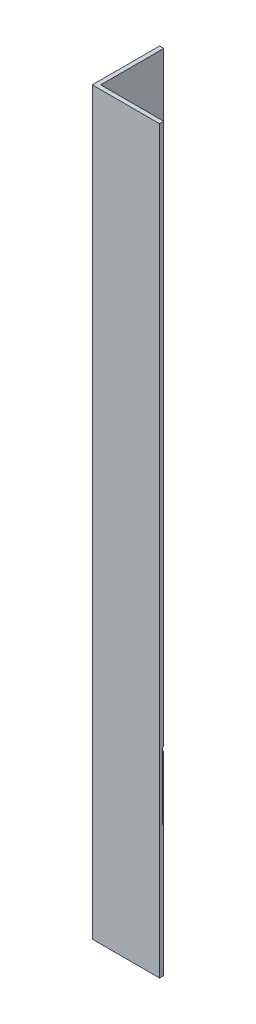
from build123d import *

# Parameters (mm, degrees)
BOSS_EXTRUDE1_DEPTH = 279.4
SKETCH4_W           = 24.315928
SKETCH4_H           = 25.4
CUT_EXTRUDE1_DEPTH  = 26.4


with BuildPart() as part:
    # Sketch1 → Boss-Extrude1 (new body)
    with BuildSketch(Plane(origin=(0, 0, 0), x_dir=(1, 0, 0), z_dir=(0, 1, 0))):
        Polygon((0, 0), (0, 25.4), (1.5875, 25.4), (1.5875, 1.5875), (25.4, 1.5875), (25.4, 0), align=None)
    extrude(amount=BOSS_EXTRUDE1_DEPTH)

    # Sketch4 → Cut-Extrude1 (cut, through all)
    with BuildSketch(Plane.ZY):
        with Locations((-13.242036, 62.3189)):
            Rectangle(SKETCH4_W, SKETCH4_H)
    extrude(amount=-CUT_EXTRUDE1_DEPTH, mode=Mode.SUBTRACT)


solid = part.part
